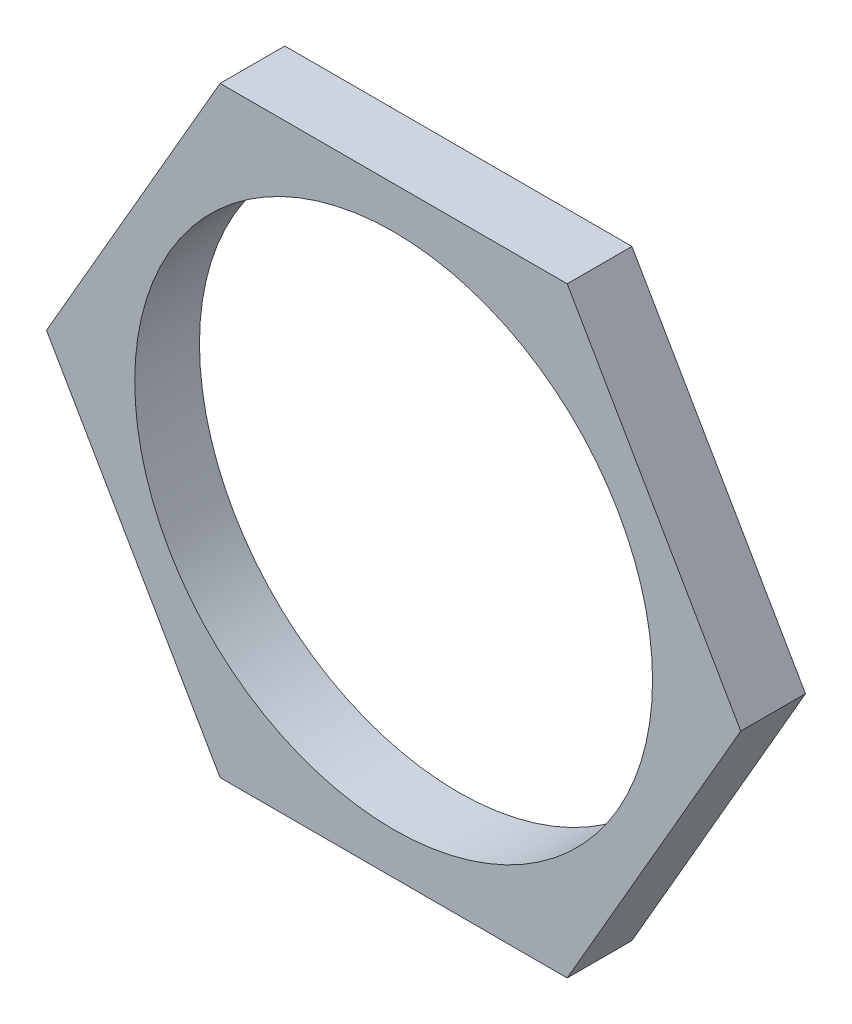
from build123d import *

# Parameters (mm, degrees)
SKETCH1_R           = 6
BOSS_EXTRUDE1_DEPTH = 1.5


with BuildPart() as part:
    # Sketch1 → Boss-Extrude1 (new body)
    with BuildSketch(Plane.XY):
        Polygon((8.044142438, 0), (4.022071219, 6.966431703), (-4.022071219, 6.966431703), (-8.044142438, 0), (-4.022071219, -6.966431703), (4.022071219, -6.966431703), align=None)
        Circle(SKETCH1_R, mode=Mode.SUBTRACT)
    extrude(amount=BOSS_EXTRUDE1_DEPTH)


solid = part.part
